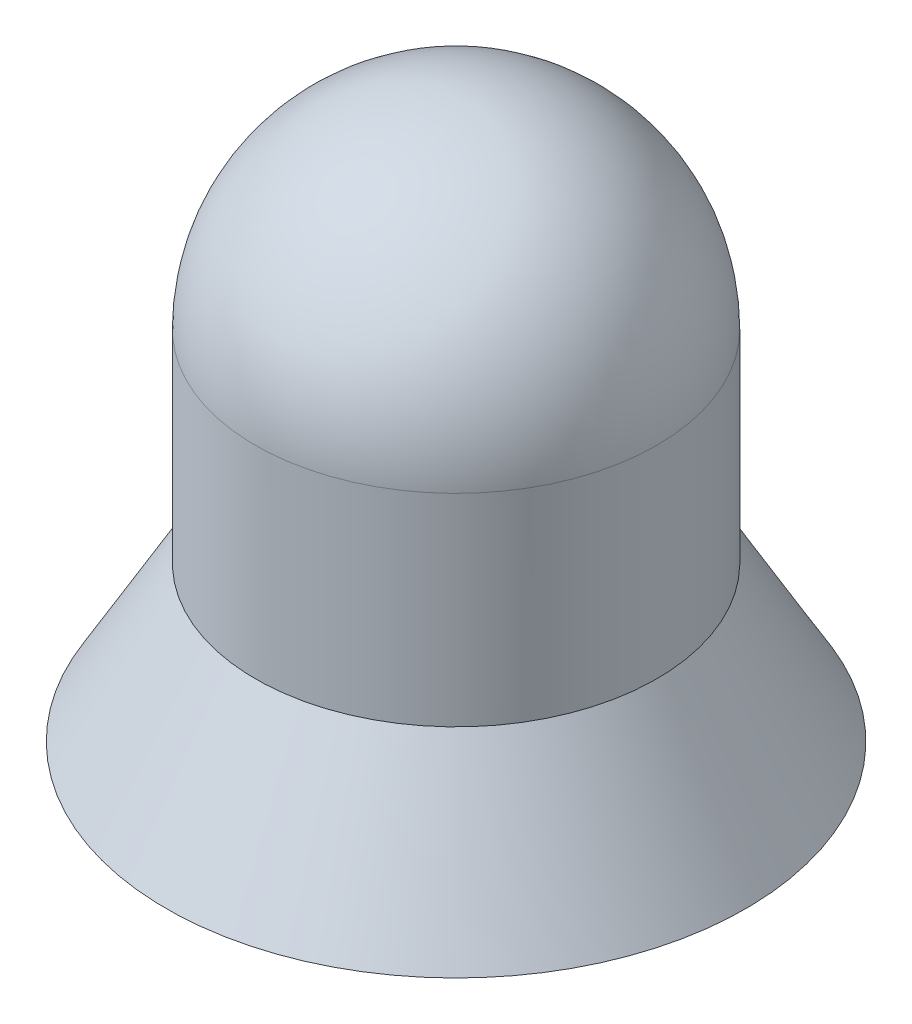
from build123d import *

# Parameters (mm, degrees)
F_1_0_1_DIAMETER_HOLE1_D     = 1
F_1_0_1_DIAMETER_HOLE1_DEPTH = 1.8
F_1_0_1_DIAMETER_HOLE1_TIP   = 0.30043031


with BuildPart() as part:
    # Sketch1 → Revolve1 (revolve)
    with BuildSketch(Plane.XY):
        with BuildLine():
            Line((1.3, 0), (0.9, 0.692820323))
            Line((0.9, 0.692820323), (0.9, 1.6))
            ThreePointArc((0.9, 1.6), (0.636396103, 2.236396103), (0, 2.5))
            Line((0, 2.5), (0, 0))
            Line((0, 0), (1.3, 0))
        make_face()
    revolve(axis=Axis((0, 0, 0), (0, 1, 0)))

    # Ø1.0 (1) Diameter Hole1
    with Locations(Plane(origin=(0, 0, 0), x_dir=(-1, 0, 0), z_dir=(0, -1, 0))):
        with Locations((0, 0)):
            Hole(F_1_0_1_DIAMETER_HOLE1_D / 2, depth=F_1_0_1_DIAMETER_HOLE1_DEPTH)
            with Locations((0, 0, -(F_1_0_1_DIAMETER_HOLE1_DEPTH + F_1_0_1_DIAMETER_HOLE1_TIP / 2))):  # 118° drill point
                Cone(0, F_1_0_1_DIAMETER_HOLE1_D / 2, F_1_0_1_DIAMETER_HOLE1_TIP, mode=Mode.SUBTRACT)


solid = part.part
